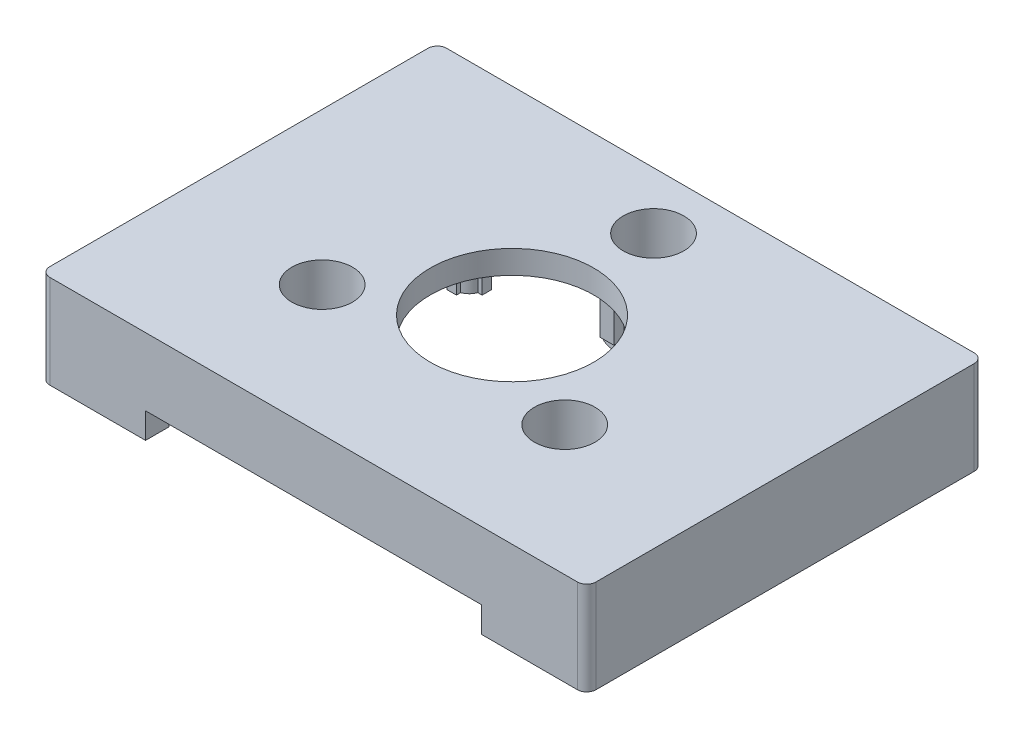
from build123d import *

# Parameters (mm, degrees)
SKETCH1_W           = 117
SKETCH1_H           = 85
BOSS_EXTRUDE1_DEPTH = 20
SKETCH2_W           = 107
SKETCH2_H           = 75
CUT_EXTRUDE1_DEPTH  = 15
FILLET1_R           = 2
FILLET2_R           = 2
FILLET3_R           = 2
FILLET4_R           = 2
SKETCH3_R           = 3.5
BOSS_EXTRUDE2_DEPTH = 16
SKETCH4_R           = 1.5
CUT_EXTRUDE2_DEPTH  = 15
SKETCH5_W           = 72
SKETCH5_H           = 5.5
CUT_EXTRUDE3_DEPTH  = 15
BOSS_EXTRUDE3_DEPTH = 10
SKETCH8_R           = 6.5
CUT_EXTRUDE4_DEPTH  = 16
SKETCH9_R           = 8
BOSS_EXTRUDE4_DEPTH = 3
SKETCH10_R          = 1.75
CUT_EXTRUDE5_DEPTH  = 3
SKETCH12_R          = 17.5
CUT_EXTRUDE6_DEPTH  = 5
BOSS_EXTRUDE6_DEPTH = 6
SKETCH14_R          = 1.5
CUT_EXTRUDE7_DEPTH  = 5
SKETCH15_R          = 1.5
CUT_EXTRUDE8_DEPTH  = 5
SKETCH16_R          = 1.5
CUT_EXTRUDE9_DEPTH  = 5
SKETCH17_W          = 61
SKETCH17_H          = 11.5
CUT_EXTRUDE10_DEPTH = 3.5
SKETCH18_R          = 3
SKETCH18_R_2        = 1.5
BOSS_EXTRUDE7_DEPTH = 2
SKETCH19_W          = 5
SKETCH19_H          = 5.5
CUT_EXTRUDE11_DEPTH = 3
SKETCH20_W          = 61
SKETCH20_H          = 2.5
CUT_EXTRUDE12_DEPTH = 3.5


with BuildPart() as part:
    # Sketch1 → Boss-Extrude1 (new body)
    with BuildSketch(Plane(origin=(0, 0, 0), x_dir=(1, 0, 0), z_dir=(0, 1, 0))):
        Rectangle(SKETCH1_W, SKETCH1_H)
    extrude(amount=BOSS_EXTRUDE1_DEPTH)

    # Sketch2 → Cut-Extrude1 (cut)
    with BuildSketch(Plane(origin=(0, 0, 0), x_dir=(-1, 0, 0), z_dir=(0, -1, 0))):
        Rectangle(SKETCH2_W, SKETCH2_H)
    extrude(amount=-CUT_EXTRUDE1_DEPTH, mode=Mode.SUBTRACT)

    # Fillet1
    fillet1_edges = [part.edges().sort_by_distance(p)[0] for p in [
        (-58.5, 10, 42.5),
    ]]
    fillet(fillet1_edges, radius=FILLET1_R)

    # Fillet2
    fillet2_edges = [part.edges().sort_by_distance(p)[0] for p in [
        (58.5, 10, 42.5),
    ]]
    fillet(fillet2_edges, radius=FILLET2_R)

    # Fillet3
    fillet3_edges = [part.edges().sort_by_distance(p)[0] for p in [
        (58.5, 10, -42.5),
    ]]
    fillet(fillet3_edges, radius=FILLET3_R)

    # Fillet4
    fillet4_edges = [part.edges().sort_by_distance(p)[0] for p in [
        (-58.5, 10, -42.5),
    ]]
    fillet(fillet4_edges, radius=FILLET4_R)

    # Sketch3 → Boss-Extrude2 (add)
    with BuildSketch(Plane.XZ):
        with Locations((-54.8, 38.8)):
            Circle(SKETCH3_R)
        with Locations((54.8, 38.8)):
            Circle(SKETCH3_R)
        with Locations((54.8, -38.8)):
            Circle(SKETCH3_R)
        with Locations((-54.8, -38.8)):
            Circle(SKETCH3_R)
    extrude(amount=-BOSS_EXTRUDE2_DEPTH)

    # Sketch4 → Cut-Extrude2 (cut)
    with BuildSketch(Plane.XZ):
        with Locations((-54.8, 38.8)):
            Circle(SKETCH4_R)
        with Locations((54.8, 38.8)):
            Circle(SKETCH4_R)
        with Locations((54.8, -38.8)):
            Circle(SKETCH4_R)
        with Locations((-54.8, -38.8)):
            Circle(SKETCH4_R)
    extrude(amount=-CUT_EXTRUDE2_DEPTH, mode=Mode.SUBTRACT)

    # Sketch5 → Cut-Extrude3 (cut)
    with BuildSketch(Plane.XY.offset(42.5)):
        with Locations((0, 2.75)):
            Rectangle(SKETCH5_W, SKETCH5_H)
    extrude(amount=-CUT_EXTRUDE3_DEPTH, mode=Mode.SUBTRACT)

    # Sketch7 → Boss-Extrude3 (add)
    with BuildSketch(Plane(origin=(0, 15, -5.315376475), x_dir=(1, 0, 0), z_dir=(0, -1, 0))):
        with BuildLine():
            Line((27.480762114, 10), (24.480762114, 10))
            Line((24.480762114, 10), (24.480762114, 12.141883177))
            ThreePointArc((24.480762114, 12.141883177), (20.323907864, 14.343145751), (18.122645291, 18.5))
            Line((18.122645291, 18.5), (15.980762114, 18.5))
            Line((15.980762114, 18.5), (15.980762114, 21.5))
            Line((15.980762114, 21.5), (18.122645291, 21.5))
            ThreePointArc((18.122645291, 21.5), (20.323907864, 25.656854249), (24.480762114, 27.858116823))
            Line((24.480762114, 27.858116823), (24.480762114, 30))
            Line((24.480762114, 30), (27.480762114, 30))
            Line((27.480762114, 30), (27.480762114, 27.858116823))
            ThreePointArc((27.480762114, 27.858116823), (31.637616363, 25.656854249), (33.838878936, 21.5))
            Line((33.838878936, 21.5), (35.980762114, 21.5))
            Line((35.980762114, 21.5), (35.980762114, 18.5))
            Line((35.980762114, 18.5), (33.838878936, 18.5))
            ThreePointArc((33.838878936, 18.5), (31.637616363, 14.343145751), (27.480762114, 12.141883177))
            Line((27.480762114, 12.141883177), (27.480762114, 10))
        make_face()
        with BuildLine():
            Line((-24.480762114, 10), (-27.480762114, 10))
            Line((-27.480762114, 10), (-27.480762114, 12.141883177))
            ThreePointArc((-27.480762114, 12.141883177), (-31.637616363, 14.343145751), (-33.838878936, 18.5))
            Line((-33.838878936, 18.5), (-35.980762114, 18.5))
            Line((-35.980762114, 18.5), (-35.980762114, 21.5))
            Line((-35.980762114, 21.5), (-33.838878936, 21.5))
            ThreePointArc((-33.838878936, 21.5), (-31.637616363, 25.656854249), (-27.480762114, 27.858116823))
            Line((-27.480762114, 27.858116823), (-27.480762114, 30))
            Line((-27.480762114, 30), (-24.480762114, 30))
            Line((-24.480762114, 30), (-24.480762114, 27.858116823))
            ThreePointArc((-24.480762114, 27.858116823), (-20.323907864, 25.656854249), (-18.122645291, 21.5))
            Line((-18.122645291, 21.5), (-15.980762114, 21.5))
            Line((-15.980762114, 21.5), (-15.980762114, 18.5))
            Line((-15.980762114, 18.5), (-18.122645291, 18.5))
            ThreePointArc((-18.122645291, 18.5), (-20.323907864, 14.343145751), (-24.480762114, 12.141883177))
            Line((-24.480762114, 12.141883177), (-24.480762114, 10))
        make_face()
        with BuildLine():
            Line((1.5, -35), (-1.5, -35))
            Line((-1.5, -35), (-1.5, -32.858116823))
            ThreePointArc((-1.5, -32.858116823), (-5.656854249, -30.656854249), (-7.858116823, -26.5))
            Line((-7.858116823, -26.5), (-10, -26.5))
            Line((-10, -26.5), (-10, -23.5))
            Line((-10, -23.5), (-7.858116823, -23.5))
            ThreePointArc((-7.858116823, -23.5), (-5.656854249, -19.343145751), (-1.5, -17.141883177))
            Line((-1.5, -17.141883177), (-1.5, -15))
            Line((-1.5, -15), (1.5, -15))
            Line((1.5, -15), (1.5, -17.141883177))
            ThreePointArc((1.5, -17.141883177), (5.656854249, -19.343145751), (7.858116823, -23.5))
            Line((7.858116823, -23.5), (10, -23.5))
            Line((10, -23.5), (10, -26.5))
            Line((10, -26.5), (7.858116823, -26.5))
            ThreePointArc((7.858116823, -26.5), (5.656854249, -30.656854249), (1.5, -32.858116823))
            Line((1.5, -32.858116823), (1.5, -35))
        make_face()
    extrude(amount=BOSS_EXTRUDE3_DEPTH)

    # Sketch8 → Cut-Extrude4 (cut, through all)
    with BuildSketch(Plane(origin=(0, 5, -5.315376475), x_dir=(1, 0, 0), z_dir=(0, -1, 0))):
        with Locations((-25.980762114, 20)):
            Circle(SKETCH8_R)
        with Locations((0, -25)):
            Circle(SKETCH8_R)
        with Locations((25.980762114, 20)):
            Circle(SKETCH8_R)
    extrude(amount=-CUT_EXTRUDE4_DEPTH, mode=Mode.SUBTRACT)

    # Sketch9 → Boss-Extrude4 (add)
    with BuildSketch(Plane(origin=(0, 5, -5.315376475), x_dir=(1, 0, 0), z_dir=(0, -1, 0))):
        with Locations((25.980762114, 20)):
            Circle(SKETCH9_R)
        with Locations((-25.980762114, 20)):
            Circle(SKETCH9_R)
        with Locations((0, -25)):
            Circle(SKETCH9_R)
    extrude(amount=BOSS_EXTRUDE4_DEPTH)

    # Sketch10 → Cut-Extrude5 (cut)
    with BuildSketch(Plane(origin=(0, 2, -5.315376475), x_dir=(1, 0, 0), z_dir=(0, -1, 0))):
        with Locations((25.980762114, 20)):
            Circle(SKETCH10_R)
        with Locations((-25.980762114, 20)):
            Circle(SKETCH10_R)
        with Locations((0, -25)):
            Circle(SKETCH10_R)
    extrude(amount=-CUT_EXTRUDE5_DEPTH, mode=Mode.SUBTRACT)

    # Sketch12 → Cut-Extrude6 (cut)
    with BuildSketch(Plane(origin=(0, 20, 0), x_dir=(1, 0, 0), z_dir=(0, 1, 0))):
        Circle(SKETCH12_R)
    extrude(amount=-CUT_EXTRUDE6_DEPTH, mode=Mode.SUBTRACT)

    # Sketch13 → Boss-Extrude6 (add)
    with BuildSketch(Plane.XZ.offset(-15)):
        with BuildLine():
            ThreePointArc((-1, 27.828427125), (0, 28), (1, 27.828427125))
            Line((1, 27.828427125), (1, 28.75))
            Line((1, 28.75), (-1, 28.75))
            Line((-1, 28.75), (-1, 27.828427125))
        make_face()
        with BuildLine():
            Line((-1, 26), (1, 26))
            Line((1, 26), (1, 27.828427125))
            ThreePointArc((1, 27.828427125), (0, 28), (-1, 27.828427125))
            Line((-1, 27.828427125), (-1, 26))
        make_face()
        with BuildLine():
            Line((1, 27.828427125), (1, 26))
            Line((1, 26), (2.828427125, 26))
            ThreePointArc((2.828427125, 26), (2.121320344, 27.121320344), (1, 27.828427125))
        make_face()
        with BuildLine():
            Line((1, 26), (1, 24.979991994))
            ThreePointArc((1, 24.979991994), (1.998898928, 24.919959933), (2.994595131, 24.82))
            ThreePointArc((2.994595131, 24.82), (2.998648478, 24.909959436), (3, 25))
            ThreePointArc((3, 25), (2.956795679, 25.507305936), (2.828427125, 26))
            Line((2.828427125, 26), (1, 26))
        make_face()
        with BuildLine():
            ThreePointArc((3, 25), (2.998648478, 24.909959436), (2.994595131, 24.82))
            ThreePointArc((2.994595131, 24.82), (3.37268964, 24.771454632), (3.75, 24.717149917))
            Line((3.75, 24.717149917), (3.75, 26))
            Line((3.75, 26), (2.828427125, 26))
            ThreePointArc((2.828427125, 26), (2.956795679, 25.507305936), (3, 25))
        make_face()
        with BuildLine():
            ThreePointArc((2.994595131, 24.82), (2.940237584, 24.404178759), (2.828427125, 24))
            Line((2.828427125, 24), (3.75, 24))
            Line((3.75, 24), (3.75, 24.717149917))
            ThreePointArc((3.75, 24.717149917), (3.37268964, 24.771454632), (2.994595131, 24.82))
        make_face()
        with BuildLine():
            Line((1, 24.979991994), (1, 24))
            Line((1, 24), (2.828427125, 24))
            ThreePointArc((2.828427125, 24), (2.940237584, 24.404178759), (2.994595131, 24.82))
            ThreePointArc((2.994595131, 24.82), (1.998898928, 24.919959933), (1, 24.979991994))
        make_face()
        with BuildLine():
            Line((1, 24), (1, 22.171572875))
            ThreePointArc((1, 22.171572875), (2.121320344, 22.878679656), (2.828427125, 24))
            Line((2.828427125, 24), (1, 24))
        make_face()
        with BuildLine():
            Line((0, 22), (0, 21.25))
            Line((0, 21.25), (1, 21.25))
            Line((1, 21.25), (1, 22.171572875))
            ThreePointArc((1, 22.171572875), (0.507305936, 22.043204321), (0, 22))
        make_face()
        with BuildLine():
            Line((-1, 21.25), (0, 21.25))
            Line((0, 21.25), (0, 22))
            ThreePointArc((0, 22), (-0.507305936, 22.043204321), (-1, 22.171572875))
            Line((-1, 22.171572875), (-1, 21.25))
        make_face()
        with BuildLine():
            ThreePointArc((-1, 22.171572875), (-0.507305936, 22.043204321), (0, 22))
            Line((0, 22), (0, 24))
            Line((0, 24), (-1, 24))
            Line((-1, 24), (-1, 22.171572875))
        make_face()
        with BuildLine():
            Line((0, 24), (0, 22))
            ThreePointArc((0, 22), (0.507305936, 22.043204321), (1, 22.171572875))
            Line((1, 22.171572875), (1, 24))
            Line((1, 24), (0, 24))
        make_face()
        with BuildLine():
            Line((0, 25), (0, 24))
            Line((0, 24), (1, 24))
            Line((1, 24), (1, 24.979991994))
            ThreePointArc((1, 24.979991994), (0.50010007, 24.994997498), (0, 25))
        make_face()
        with BuildLine():
            Line((-1, 24), (0, 24))
            Line((0, 24), (0, 25))
            ThreePointArc((0, 25), (-0.50010007, 24.994997498), (-1, 24.979991994))
            Line((-1, 24.979991994), (-1, 24))
        make_face()
        with BuildLine():
            ThreePointArc((-1, 24.979991994), (-0.50010007, 24.994997498), (0, 25))
            ThreePointArc((0, 25), (0.50010007, 24.994997498), (1, 24.979991994))
            Line((1, 24.979991994), (1, 26))
            Line((1, 26), (-1, 26))
            Line((-1, 26), (-1, 24.979991994))
        make_face()
        with BuildLine():
            ThreePointArc((-2.994595131, 24.82), (-1.998898928, 24.919959933), (-1, 24.979991994))
            Line((-1, 24.979991994), (-1, 26))
            Line((-1, 26), (-2.828427125, 26))
            ThreePointArc((-2.828427125, 26), (-2.970689659, 25.418333541), (-2.994595131, 24.82))
        make_face()
        with BuildLine():
            Line((-2.828427125, 26), (-1, 26))
            Line((-1, 26), (-1, 27.828427125))
            ThreePointArc((-1, 27.828427125), (-2.121320344, 27.121320344), (-2.828427125, 26))
        make_face()
        with BuildLine():
            ThreePointArc((-3.75, 24.717149917), (-3.37268964, 24.771454632), (-2.994595131, 24.82))
            ThreePointArc((-2.994595131, 24.82), (-2.970689659, 25.418333541), (-2.828427125, 26))
            Line((-2.828427125, 26), (-3.75, 26))
            Line((-3.75, 26), (-3.75, 24.717149917))
        make_face()
        with BuildLine():
            Line((-3.75, 24), (-2.828427125, 24))
            ThreePointArc((-2.828427125, 24), (-2.940237584, 24.404178759), (-2.994595131, 24.82))
            ThreePointArc((-2.994595131, 24.82), (-3.37268964, 24.771454632), (-3.75, 24.717149917))
            Line((-3.75, 24.717149917), (-3.75, 24))
        make_face()
        with BuildLine():
            Line((-2.828427125, 24), (-1, 24))
            Line((-1, 24), (-1, 24.979991994))
            ThreePointArc((-1, 24.979991994), (-1.998898928, 24.919959933), (-2.994595131, 24.82))
            ThreePointArc((-2.994595131, 24.82), (-2.940237584, 24.404178759), (-2.828427125, 24))
        make_face()
        with BuildLine():
            ThreePointArc((-2.828427125, 24), (-2.121320344, 22.878679656), (-1, 22.171572875))
            Line((-1, 22.171572875), (-1, 24))
            Line((-1, 24), (-2.828427125, 24))
        make_face()
        with BuildLine():
            Line((20.650635095, -8.75), (20.650635095, -9.671572875))
            ThreePointArc((20.650635095, -9.671572875), (21.650635095, -9.5), (22.650635095, -9.671572875))
            Line((22.650635095, -9.671572875), (22.650635095, -8.75))
            Line((22.650635095, -8.75), (20.650635095, -8.75))
        make_face()
        with BuildLine():
            Line((20.650635095, -9.671572875), (20.650635095, -10.909177803))
            ThreePointArc((20.650635095, -10.909177803), (20.848223288, -11.203203787), (21.041625413, -11.5))
            Line((21.041625413, -11.5), (22.19797288, -11.5))
            ThreePointArc((22.19797288, -11.5), (22.429015613, -11.042611042), (22.650635095, -10.580582678))
            Line((22.650635095, -10.580582678), (22.650635095, -9.671572875))
            ThreePointArc((22.650635095, -9.671572875), (21.650635095, -9.5), (20.650635095, -9.671572875))
        make_face()
        with BuildLine():
            ThreePointArc((21.041625413, -11.5), (20.848223288, -11.203203787), (20.650635095, -10.909177803))
            Line((20.650635095, -10.909177803), (20.650635095, -11.5))
            Line((20.650635095, -11.5), (21.041625413, -11.5))
        make_face()
        with BuildLine():
            ThreePointArc((22.650635095, -10.580582678), (22.429015613, -11.042611042), (22.19797288, -11.5))
            Line((22.19797288, -11.5), (22.650635095, -11.5))
            Line((22.650635095, -11.5), (22.650635095, -10.580582678))
        make_face()
        with BuildLine():
            ThreePointArc((22.992048088, -9.816604542), (22.823585327, -9.738806824), (22.650635095, -9.671572875))
            Line((22.650635095, -9.671572875), (22.650635095, -10.580582678))
            ThreePointArc((22.650635095, -10.580582678), (22.824538279, -10.200022173), (22.992048088, -9.816604542))
        make_face()
        with BuildLine():
            ThreePointArc((20.650635095, -9.671572875), (20.314126486, -9.814158467), (19.997452956, -9.996604542))
            ThreePointArc((19.997452956, -9.996604542), (20.329165331, -10.449225555), (20.650635095, -10.909177803))
            Line((20.650635095, -10.909177803), (20.650635095, -9.671572875))
        make_face()
        with BuildLine():
            ThreePointArc((20.650635095, -10.909177803), (20.329165331, -10.449225555), (19.997452956, -9.996604542))
            ThreePointArc((19.997452956, -9.996604542), (19.287109154, -10.652367697), (18.82220797, -11.5))
            Line((18.82220797, -11.5), (20.650635095, -11.5))
            Line((20.650635095, -11.5), (20.650635095, -10.909177803))
        make_face()
        with BuildLine():
            ThreePointArc((22.992048088, -9.816604542), (22.824538279, -10.200022173), (22.650635095, -10.580582678))
            Line((22.650635095, -10.580582678), (22.650635095, -11.5))
            Line((22.650635095, -11.5), (24.479062219, -11.5))
            ThreePointArc((24.479062219, -11.5), (23.899044915, -10.513884877), (22.992048088, -9.816604542))
        make_face()
        with BuildLine():
            Line((24.479062219, -11.5), (22.650635095, -11.5))
            Line((22.650635095, -11.5), (22.650635095, -13.5))
            Line((22.650635095, -13.5), (24.479062219, -13.5))
            ThreePointArc((24.479062219, -13.5), (24.607430774, -13.007305936), (24.650635095, -12.5))
            ThreePointArc((24.650635095, -12.5), (24.607430774, -11.992694064), (24.479062219, -11.5))
        make_face()
        with BuildLine():
            Line((25.400635095, -11.5), (24.479062219, -11.5))
            ThreePointArc((24.479062219, -11.5), (24.607430774, -11.992694064), (24.650635095, -12.5))
            ThreePointArc((24.650635095, -12.5), (24.607430774, -13.007305936), (24.479062219, -13.5))
            Line((24.479062219, -13.5), (25.400635095, -13.5))
            Line((25.400635095, -13.5), (25.400635095, -11.5))
        make_face()
        with BuildLine():
            Line((22.650635095, -13.5), (22.650635095, -14.419417322))
            ThreePointArc((22.650635095, -14.419417322), (22.824538279, -14.799977827), (22.992048088, -15.183395458))
            ThreePointArc((22.992048088, -15.183395458), (23.899044915, -14.486115123), (24.479062219, -13.5))
            Line((24.479062219, -13.5), (22.650635095, -13.5))
        make_face()
        with BuildLine():
            Line((22.650635095, -14.419417322), (22.650635095, -15.328427125))
            ThreePointArc((22.650635095, -15.328427125), (22.823585327, -15.261193176), (22.992048088, -15.183395458))
            ThreePointArc((22.992048088, -15.183395458), (22.824538279, -14.799977827), (22.650635095, -14.419417322))
        make_face()
        with BuildLine():
            Line((22.650635095, -13.5), (22.19797288, -13.5))
            ThreePointArc((22.19797288, -13.5), (22.429015613, -13.957388958), (22.650635095, -14.419417322))
            Line((22.650635095, -14.419417322), (22.650635095, -13.5))
        make_face()
        with BuildLine():
            Line((22.650635095, -11.5), (22.19797288, -11.5))
            ThreePointArc((22.19797288, -11.5), (21.930004682, -12.003120205), (21.650635095, -12.5))
            ThreePointArc((21.650635095, -12.5), (21.930004682, -12.996879795), (22.19797288, -13.5))
            Line((22.19797288, -13.5), (22.650635095, -13.5))
            Line((22.650635095, -13.5), (22.650635095, -11.5))
        make_face()
        with BuildLine():
            Line((22.19797288, -11.5), (21.041625413, -11.5))
            ThreePointArc((21.041625413, -11.5), (21.351985313, -11.996434212), (21.650635095, -12.5))
            ThreePointArc((21.650635095, -12.5), (21.930004682, -12.003120205), (22.19797288, -11.5))
        make_face()
        with BuildLine():
            Line((21.041625413, -11.5), (20.650635095, -11.5))
            Line((20.650635095, -11.5), (20.650635095, -13.5))
            Line((20.650635095, -13.5), (21.041625413, -13.5))
            ThreePointArc((21.041625413, -13.5), (21.351985313, -13.003565788), (21.650635095, -12.5))
            ThreePointArc((21.650635095, -12.5), (21.351985313, -11.996434212), (21.041625413, -11.5))
        make_face()
        with BuildLine():
            ThreePointArc((21.650635095, -12.5), (21.351985313, -13.003565788), (21.041625413, -13.5))
            Line((21.041625413, -13.5), (22.19797288, -13.5))
            ThreePointArc((22.19797288, -13.5), (21.930004682, -12.996879795), (21.650635095, -12.5))
        make_face()
        with BuildLine():
            ThreePointArc((21.041625413, -13.5), (20.848223288, -13.796796213), (20.650635095, -14.090822197))
            Line((20.650635095, -14.090822197), (20.650635095, -15.328427125))
            ThreePointArc((20.650635095, -15.328427125), (21.650635095, -15.5), (22.650635095, -15.328427125))
            Line((22.650635095, -15.328427125), (22.650635095, -14.419417322))
            ThreePointArc((22.650635095, -14.419417322), (22.429015613, -13.957388958), (22.19797288, -13.5))
            Line((22.19797288, -13.5), (21.041625413, -13.5))
        make_face()
        with BuildLine():
            Line((20.650635095, -13.5), (20.650635095, -14.090822197))
            ThreePointArc((20.650635095, -14.090822197), (20.848223288, -13.796796213), (21.041625413, -13.5))
            Line((21.041625413, -13.5), (20.650635095, -13.5))
        make_face()
        with BuildLine():
            ThreePointArc((18.82220797, -13.5), (19.287109154, -14.347632303), (19.997452956, -15.003395458))
            ThreePointArc((19.997452956, -15.003395458), (20.329165331, -14.550774445), (20.650635095, -14.090822197))
            Line((20.650635095, -14.090822197), (20.650635095, -13.5))
            Line((20.650635095, -13.5), (18.82220797, -13.5))
        make_face()
        with BuildLine():
            ThreePointArc((20.650635095, -14.090822197), (20.329165331, -14.550774445), (19.997452956, -15.003395458))
            ThreePointArc((19.997452956, -15.003395458), (20.314126486, -15.185841533), (20.650635095, -15.328427125))
            Line((20.650635095, -15.328427125), (20.650635095, -14.090822197))
        make_face()
        with BuildLine():
            Line((20.650635095, -11.5), (18.82220797, -11.5))
            ThreePointArc((18.82220797, -11.5), (18.650635095, -12.5), (18.82220797, -13.5))
            Line((18.82220797, -13.5), (20.650635095, -13.5))
            Line((20.650635095, -13.5), (20.650635095, -11.5))
        make_face()
        with BuildLine():
            ThreePointArc((18.82220797, -13.5), (18.650635095, -12.5), (18.82220797, -11.5))
            Line((18.82220797, -11.5), (17.900635095, -11.5))
            Line((17.900635095, -11.5), (17.900635095, -13.5))
            Line((17.900635095, -13.5), (18.82220797, -13.5))
        make_face()
        with BuildLine():
            ThreePointArc((-21.041625413, -11.5), (-20.848223288, -11.203203787), (-20.650635095, -10.909177803))
            Line((-20.650635095, -10.909177803), (-20.650635095, -9.671572875))
            ThreePointArc((-20.650635095, -9.671572875), (-21.650635095, -9.5), (-22.650635095, -9.671572875))
            Line((-22.650635095, -9.671572875), (-22.650635095, -10.580582678))
            ThreePointArc((-22.650635095, -10.580582678), (-22.429015613, -11.042611042), (-22.19797288, -11.5))
            Line((-22.19797288, -11.5), (-21.041625413, -11.5))
        make_face()
        with BuildLine():
            ThreePointArc((-22.650635095, -9.671572875), (-21.650635095, -9.5), (-20.650635095, -9.671572875))
            Line((-20.650635095, -9.671572875), (-20.650635095, -8.75))
            Line((-20.650635095, -8.75), (-22.650635095, -8.75))
            Line((-22.650635095, -8.75), (-22.650635095, -9.671572875))
        make_face()
        with BuildLine():
            ThreePointArc((-24.479062219, -13.5), (-24.650635095, -12.5), (-24.479062219, -11.5))
            Line((-24.479062219, -11.5), (-25.400635095, -11.5))
            Line((-25.400635095, -11.5), (-25.400635095, -13.5))
            Line((-25.400635095, -13.5), (-24.479062219, -13.5))
        make_face()
        with BuildLine():
            Line((-22.650635095, -13.5), (-22.650635095, -11.5))
            Line((-22.650635095, -11.5), (-24.479062219, -11.5))
            ThreePointArc((-24.479062219, -11.5), (-24.650635095, -12.5), (-24.479062219, -13.5))
            Line((-24.479062219, -13.5), (-22.650635095, -13.5))
        make_face()
        with BuildLine():
            ThreePointArc((-18.650635095, -12.5), (-18.693839416, -11.992694064), (-18.82220797, -11.5))
            Line((-18.82220797, -11.5), (-20.650635095, -11.5))
            Line((-20.650635095, -11.5), (-20.650635095, -13.5))
            Line((-20.650635095, -13.5), (-18.82220797, -13.5))
            ThreePointArc((-18.82220797, -13.5), (-18.693839416, -13.007305936), (-18.650635095, -12.5))
        make_face()
        with BuildLine():
            ThreePointArc((-20.650635095, -14.090822197), (-20.329165331, -14.550774445), (-19.997452956, -15.003395458))
            ThreePointArc((-19.997452956, -15.003395458), (-19.287109154, -14.347632303), (-18.82220797, -13.5))
            Line((-18.82220797, -13.5), (-20.650635095, -13.5))
            Line((-20.650635095, -13.5), (-20.650635095, -14.090822197))
        make_face()
        with BuildLine():
            Line((-20.650635095, -15.328427125), (-20.650635095, -14.090822197))
            ThreePointArc((-20.650635095, -14.090822197), (-20.848223288, -13.796796213), (-21.041625413, -13.5))
            Line((-21.041625413, -13.5), (-22.19797288, -13.5))
            ThreePointArc((-22.19797288, -13.5), (-22.429015613, -13.957388958), (-22.650635095, -14.419417322))
            Line((-22.650635095, -14.419417322), (-22.650635095, -15.328427125))
            ThreePointArc((-22.650635095, -15.328427125), (-21.650635095, -15.5), (-20.650635095, -15.328427125))
        make_face()
        with BuildLine():
            ThreePointArc((-22.992048088, -15.183395458), (-22.824538279, -14.799977827), (-22.650635095, -14.419417322))
            Line((-22.650635095, -14.419417322), (-22.650635095, -13.5))
            Line((-22.650635095, -13.5), (-24.479062219, -13.5))
            ThreePointArc((-24.479062219, -13.5), (-23.899044915, -14.486115123), (-22.992048088, -15.183395458))
        make_face()
        with BuildLine():
            ThreePointArc((-21.650635095, -12.5), (-21.930004682, -12.003120205), (-22.19797288, -11.5))
            Line((-22.19797288, -11.5), (-22.650635095, -11.5))
            Line((-22.650635095, -11.5), (-22.650635095, -13.5))
            Line((-22.650635095, -13.5), (-22.19797288, -13.5))
            ThreePointArc((-22.19797288, -13.5), (-21.930004682, -12.996879795), (-21.650635095, -12.5))
        make_face()
        with BuildLine():
            Line((-20.650635095, -13.5), (-20.650635095, -11.5))
            Line((-20.650635095, -11.5), (-21.041625413, -11.5))
            ThreePointArc((-21.041625413, -11.5), (-21.351985313, -11.996434212), (-21.650635095, -12.5))
            ThreePointArc((-21.650635095, -12.5), (-21.351985313, -13.003565788), (-21.041625413, -13.5))
            Line((-21.041625413, -13.5), (-20.650635095, -13.5))
        make_face()
        with BuildLine():
            Line((-22.19797288, -13.5), (-21.041625413, -13.5))
            ThreePointArc((-21.041625413, -13.5), (-21.351985313, -13.003565788), (-21.650635095, -12.5))
            ThreePointArc((-21.650635095, -12.5), (-21.930004682, -12.996879795), (-22.19797288, -13.5))
        make_face()
        with BuildLine():
            ThreePointArc((-21.650635095, -12.5), (-21.351985313, -11.996434212), (-21.041625413, -11.5))
            Line((-21.041625413, -11.5), (-22.19797288, -11.5))
            ThreePointArc((-22.19797288, -11.5), (-21.930004682, -12.003120205), (-21.650635095, -12.5))
        make_face()
        with BuildLine():
            Line((-22.650635095, -11.5), (-22.19797288, -11.5))
            ThreePointArc((-22.19797288, -11.5), (-22.429015613, -11.042611042), (-22.650635095, -10.580582678))
            Line((-22.650635095, -10.580582678), (-22.650635095, -11.5))
        make_face()
        with BuildLine():
            Line((-22.650635095, -11.5), (-22.650635095, -10.580582678))
            ThreePointArc((-22.650635095, -10.580582678), (-22.824538279, -10.200022173), (-22.992048088, -9.816604542))
            ThreePointArc((-22.992048088, -9.816604542), (-23.899044915, -10.513884877), (-24.479062219, -11.5))
            Line((-24.479062219, -11.5), (-22.650635095, -11.5))
        make_face()
        with BuildLine():
            Line((-22.650635095, -10.580582678), (-22.650635095, -9.671572875))
            ThreePointArc((-22.650635095, -9.671572875), (-22.823585327, -9.738806824), (-22.992048088, -9.816604542))
            ThreePointArc((-22.992048088, -9.816604542), (-22.824538279, -10.200022173), (-22.650635095, -10.580582678))
        make_face()
        with BuildLine():
            ThreePointArc((-20.650635095, -10.909177803), (-20.329165331, -10.449225555), (-19.997452956, -9.996604542))
            ThreePointArc((-19.997452956, -9.996604542), (-20.314126486, -9.814158467), (-20.650635095, -9.671572875))
            Line((-20.650635095, -9.671572875), (-20.650635095, -10.909177803))
        make_face()
        with BuildLine():
            ThreePointArc((-18.82220797, -11.5), (-19.287109154, -10.652367697), (-19.997452956, -9.996604542))
            ThreePointArc((-19.997452956, -9.996604542), (-20.329165331, -10.449225555), (-20.650635095, -10.909177803))
            Line((-20.650635095, -10.909177803), (-20.650635095, -11.5))
            Line((-20.650635095, -11.5), (-18.82220797, -11.5))
        make_face()
        with BuildLine():
            Line((-20.650635095, -11.5), (-20.650635095, -10.909177803))
            ThreePointArc((-20.650635095, -10.909177803), (-20.848223288, -11.203203787), (-21.041625413, -11.5))
            Line((-21.041625413, -11.5), (-20.650635095, -11.5))
        make_face()
        with BuildLine():
            ThreePointArc((-22.650635095, -14.419417322), (-22.429015613, -13.957388958), (-22.19797288, -13.5))
            Line((-22.19797288, -13.5), (-22.650635095, -13.5))
            Line((-22.650635095, -13.5), (-22.650635095, -14.419417322))
        make_face()
        with BuildLine():
            ThreePointArc((-21.041625413, -13.5), (-20.848223288, -13.796796213), (-20.650635095, -14.090822197))
            Line((-20.650635095, -14.090822197), (-20.650635095, -13.5))
            Line((-20.650635095, -13.5), (-21.041625413, -13.5))
        make_face()
        with BuildLine():
            ThreePointArc((-20.650635095, -15.328427125), (-20.314126486, -15.185841533), (-19.997452956, -15.003395458))
            ThreePointArc((-19.997452956, -15.003395458), (-20.329165331, -14.550774445), (-20.650635095, -14.090822197))
            Line((-20.650635095, -14.090822197), (-20.650635095, -15.328427125))
        make_face()
        with BuildLine():
            ThreePointArc((-22.992048088, -15.183395458), (-22.823585327, -15.261193176), (-22.650635095, -15.328427125))
            Line((-22.650635095, -15.328427125), (-22.650635095, -14.419417322))
            ThreePointArc((-22.650635095, -14.419417322), (-22.824538279, -14.799977827), (-22.992048088, -15.183395458))
        make_face()
        with BuildLine():
            Line((-17.900635095, -11.5), (-18.82220797, -11.5))
            ThreePointArc((-18.82220797, -11.5), (-18.693839416, -11.992694064), (-18.650635095, -12.5))
            ThreePointArc((-18.650635095, -12.5), (-18.693839416, -13.007305936), (-18.82220797, -13.5))
            Line((-18.82220797, -13.5), (-17.900635095, -13.5))
            Line((-17.900635095, -13.5), (-17.900635095, -11.5))
        make_face()
        with BuildLine():
            Line((-20.650635095, -16.25), (-20.650635095, -15.328427125))
            ThreePointArc((-20.650635095, -15.328427125), (-21.650635095, -15.5), (-22.650635095, -15.328427125))
            Line((-22.650635095, -15.328427125), (-22.650635095, -16.25))
            Line((-22.650635095, -16.25), (-20.650635095, -16.25))
        make_face()
        with BuildLine():
            ThreePointArc((22.650635095, -15.328427125), (21.650635095, -15.5), (20.650635095, -15.328427125))
            Line((20.650635095, -15.328427125), (20.650635095, -16.25))
            Line((20.650635095, -16.25), (22.650635095, -16.25))
            Line((22.650635095, -16.25), (22.650635095, -15.328427125))
        make_face()
    extrude(amount=BOSS_EXTRUDE6_DEPTH)

    # Sketch14 → Cut-Extrude7 (cut)
    with BuildSketch(Plane.XZ.offset(-9)):
        with Locations((21.650635095, -12.5)):
            Circle(SKETCH14_R)
    extrude(amount=-CUT_EXTRUDE7_DEPTH, mode=Mode.SUBTRACT)

    # Sketch15 → Cut-Extrude8 (cut)
    with BuildSketch(Plane.XZ.offset(-9)):
        with Locations((-21.650635095, -12.5)):
            Circle(SKETCH15_R)
    extrude(amount=-CUT_EXTRUDE8_DEPTH, mode=Mode.SUBTRACT)

    # Sketch16 → Cut-Extrude9 (cut)
    with BuildSketch(Plane.XZ.offset(-9)):
        with Locations((0, 25)):
            Circle(SKETCH16_R)
    extrude(amount=-CUT_EXTRUDE9_DEPTH, mode=Mode.SUBTRACT)

    # Sketch17 → Cut-Extrude10 (cut)
    with BuildSketch(Plane(origin=(-53.5, 0, 0), x_dir=(0, 0, -1), z_dir=(1, 0, 0))):
        with Locations((-0.000384638, 5.75)):
            Rectangle(SKETCH17_W, SKETCH17_H)
    extrude(amount=-CUT_EXTRUDE10_DEPTH, mode=Mode.SUBTRACT)

    # Sketch18 → Boss-Extrude7 (add)
    with BuildSketch(Plane(origin=(-57, 0, 0), x_dir=(0, 0, -1), z_dir=(1, 0, 0))):
        with Locations((23.999615362, 4)):
            Circle(SKETCH18_R)
        with Locations((23.999615362, 4)):
            Circle(SKETCH18_R_2, mode=Mode.SUBTRACT)
        with Locations((-14.000384638, 8.95)):
            Circle(SKETCH18_R)
        with Locations((-14.000384638, 8.95)):
            Circle(SKETCH18_R_2, mode=Mode.SUBTRACT)
    extrude(amount=BOSS_EXTRUDE7_DEPTH)

    # Sketch19 → Cut-Extrude11 (cut)
    with BuildSketch(Plane(origin=(0, 0, 37.5), x_dir=(-1, 0, 0), z_dir=(0, 0, -1))):
        with Locations((-38.5, 2.75)):
            Rectangle(SKETCH19_W, SKETCH19_H)
    extrude(amount=-CUT_EXTRUDE11_DEPTH, mode=Mode.SUBTRACT)

    # Sketch20 → Cut-Extrude12 (cut)
    with BuildSketch(Plane(origin=(-53.5, 0, 0), x_dir=(0, 0, -1), z_dir=(1, 0, 0))):
        with Locations((-0.000384638, 12.75)):
            Rectangle(SKETCH20_W, SKETCH20_H)
    extrude(amount=-CUT_EXTRUDE12_DEPTH, mode=Mode.SUBTRACT)


solid = part.part
